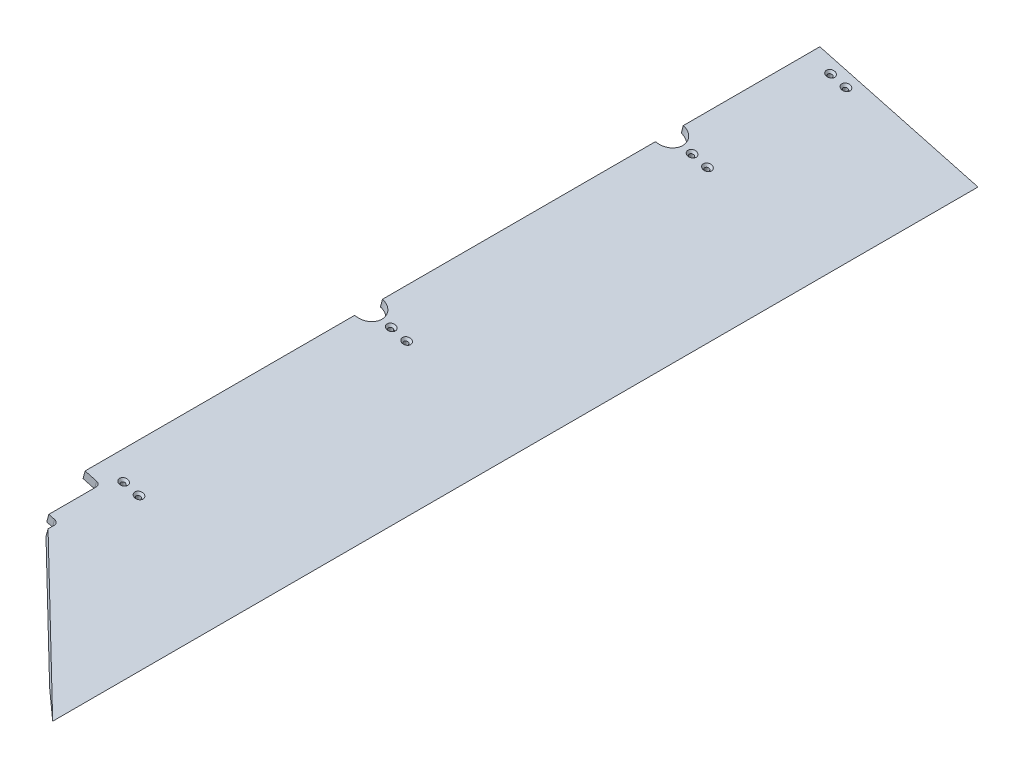
from build123d import *

# Parameters (mm, degrees)
BOSS_EXTRUDE1_DEPTH                                 = 1479.55
CSK_FOR_1_4_FLAT_HEAD_SOCKET_CAP_SCREW1_D           = 7.14248
CSK_FOR_1_4_FLAT_HEAD_SOCKET_CAP_SCREW1_CSINK_D     = 13.4874
CSK_FOR_1_4_FLAT_HEAD_SOCKET_CAP_SCREW1_CSINK_ANGLE = 82
SKETCH4_R                                           = 22.225
CUT_EXTRUDE1_DEPTH                                  = 67.312434508
CUT_EXTRUDE2_DEPTH                                  = 67.312434508
FILLET1_R                                           = 6.35


with BuildPart() as part:
    # Sketch1 → Boss-Extrude1 (new body)
    with BuildSketch(Plane.XY):
        Polygon((22.225, 55.50367642), (229.367540407, 0), (278.436572382, 0), (25.512001873, 67.770934414), align=None)
    extrude(amount=BOSS_EXTRUDE1_DEPTH)

    # CSK for 1/4 Flat Head Socket Cap Screw1 (through all)
    with Locations(Plane(origin=(18.651713678, 69.609143096, 0), x_dir=(0.965925826, -0.258819045, 0), z_dir=(0.258819045, 0.965925826, 0))):
        with Locations((44.668892959, -721.51875), (70.068892959, -721.51875), (44.668892959, -240.50625), (70.068892959, -240.50625), (44.668892959, -1149.35), (70.068892959, -1149.35), (44.668892959, -19.05), (70.068892959, -19.05)):
            CounterSinkHole(CSK_FOR_1_4_FLAT_HEAD_SOCKET_CAP_SCREW1_D / 2, CSK_FOR_1_4_FLAT_HEAD_SOCKET_CAP_SCREW1_CSINK_D / 2, counter_sink_angle=CSK_FOR_1_4_FLAT_HEAD_SOCKET_CAP_SCREW1_CSINK_ANGLE)

    # Sketch4 → Cut-Extrude1 (cut, through all)
    with BuildSketch(Plane(origin=(18.651713678, 69.609143096, 0), x_dir=(0.965925826, -0.258819045, 0), z_dir=(0.258819045, 0.965925826, 0))):
        with Locations((7.102292959, -240.50625)):
            Circle(SKETCH4_R)
        with Locations((7.102292959, -721.51875)):
            Circle(SKETCH4_R)
    extrude(amount=-CUT_EXTRUDE1_DEPTH, mode=Mode.SUBTRACT)

    # Sketch5 → Cut-Extrude2 (cut, through all)
    with BuildSketch(Plane(origin=(18.651713678, 69.609143096, 0), x_dir=(0.965925826, -0.258819045, 0), z_dir=(0.258819045, 0.965925826, 0))):
        Polygon((268.949076248, -1479.55), (48.377292959, -1273.863484507), (48.377292959, -1257.3), (32.502292959, -1257.3), (32.502292959, -1174.75), (7.102292959, -1174.75), (7.102292959, -1479.55), align=None)
    extrude(amount=-CUT_EXTRUDE2_DEPTH, mode=Mode.SUBTRACT)

    # Fillet1
    fillet1_edges = [part.edges().sort_by_distance(p)[0] for p in [
        (63.737089416, 50.954549331, 1257.3),
        (48.403016924, 55.063301672, 1174.75),
    ]]
    fillet(fillet1_edges, radius=FILLET1_R)


solid = part.part
